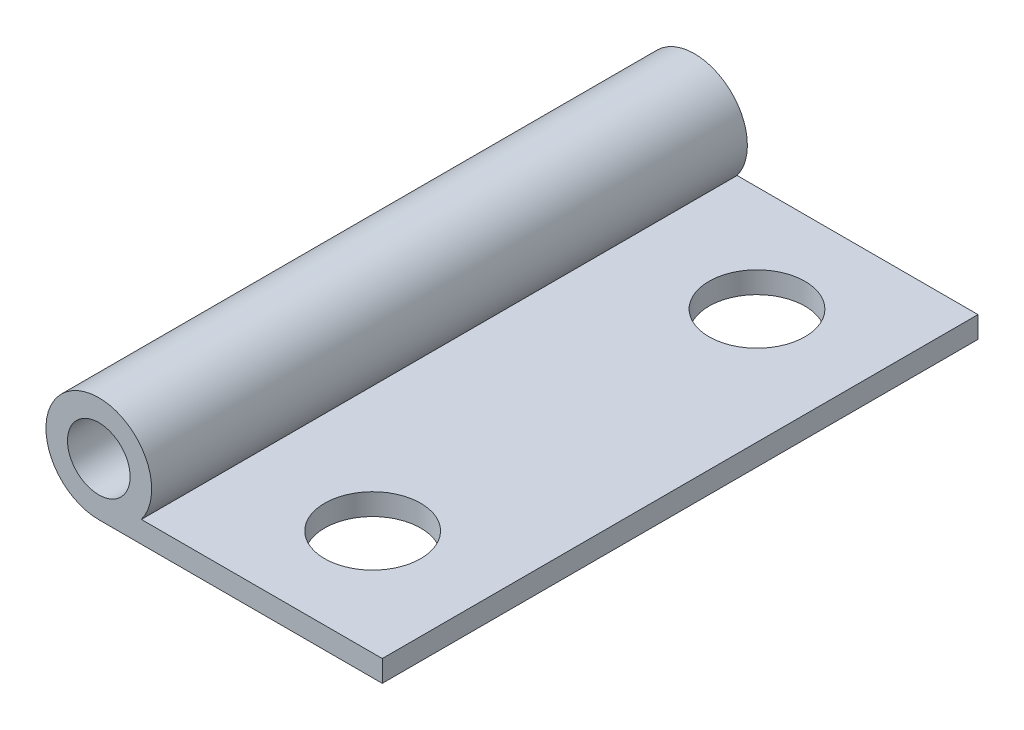
from build123d import *

# Parameters (mm, degrees)
SKETCH1_W           = 12
SKETCH1_H           = 31
SKETCH1_R           = 2.5
BOSS_EXTRUDE1_DEPTH = 1.12
SKETCH2_R           = 1.63
BOSS_EXTRUDE2_DEPTH = 31


with BuildPart() as part:
    # Sketch1 → Boss-Extrude1 (new body)
    with BuildSketch(Plane(origin=(0, 0, 0), x_dir=(1, 0, 0), z_dir=(0, 1, 0))):
        Rectangle(SKETCH1_W, SKETCH1_H)
        with Locations((0, 10)):
            Circle(SKETCH1_R, mode=Mode.SUBTRACT)
        with Locations((0, -10)):
            Circle(SKETCH1_R, mode=Mode.SUBTRACT)
    extrude(amount=BOSS_EXTRUDE1_DEPTH)

    # Sketch2 → Boss-Extrude2 (add)
    with BuildSketch(Plane.XY.offset(15.5)):
        with BuildLine():
            Line((-6, 1.12), (-6.535141088, 1.12))
            ThreePointArc((-6.535141088, 1.12), (-9.990967365, 5.204078238), (-8.75, 0))
            Line((-8.75, 0), (-6, 0))
            Line((-6, 0), (-6, 1.12))
        make_face()
        with Locations((-8.75, 2.75)):
            Circle(SKETCH2_R, mode=Mode.SUBTRACT)
    extrude(amount=-BOSS_EXTRUDE2_DEPTH)


solid = part.part
